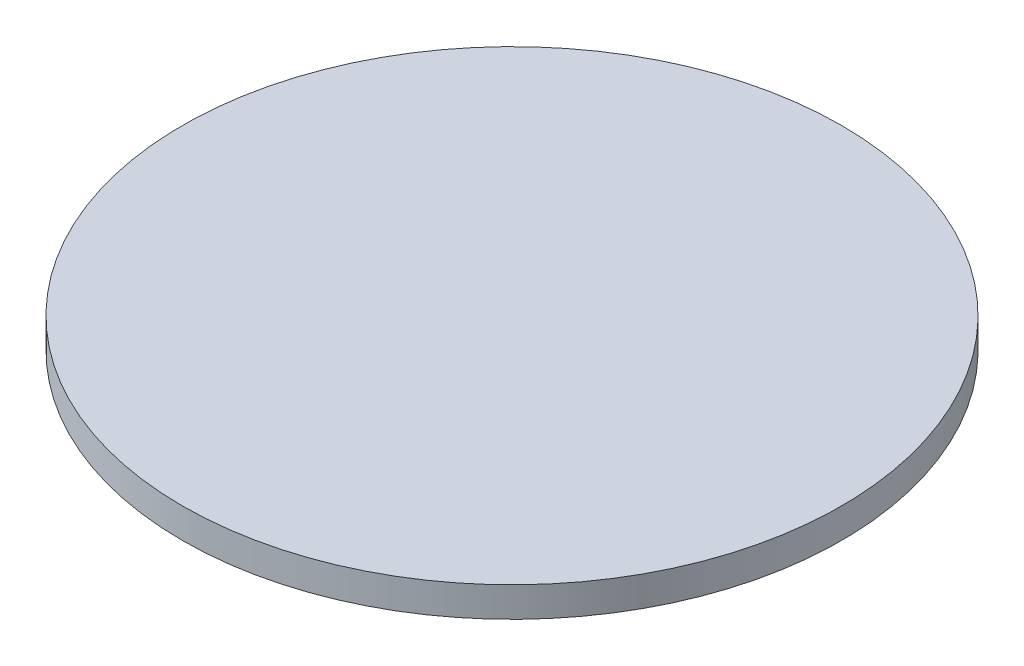
from build123d import *

# Parameters (mm, degrees)
SKETCH1_R           = 11
BOSS_EXTRUDE1_DEPTH = 1
SKETCH2_R           = 0.5
BOSS_EXTRUDE2_DEPTH = 2.5


with BuildPart() as part:
    # Sketch1 → Boss-Extrude1 (new body)
    with BuildSketch(Plane(origin=(0, 0, 0), x_dir=(1, 0, 0), z_dir=(0, 1, 0))):
        Circle(SKETCH1_R)
    extrude(amount=BOSS_EXTRUDE1_DEPTH)

    # Sketch2 → Boss-Extrude2 (add)
    with BuildSketch(Plane.XZ):
        Circle(SKETCH2_R)
    extrude(amount=BOSS_EXTRUDE2_DEPTH)


solid = part.part
